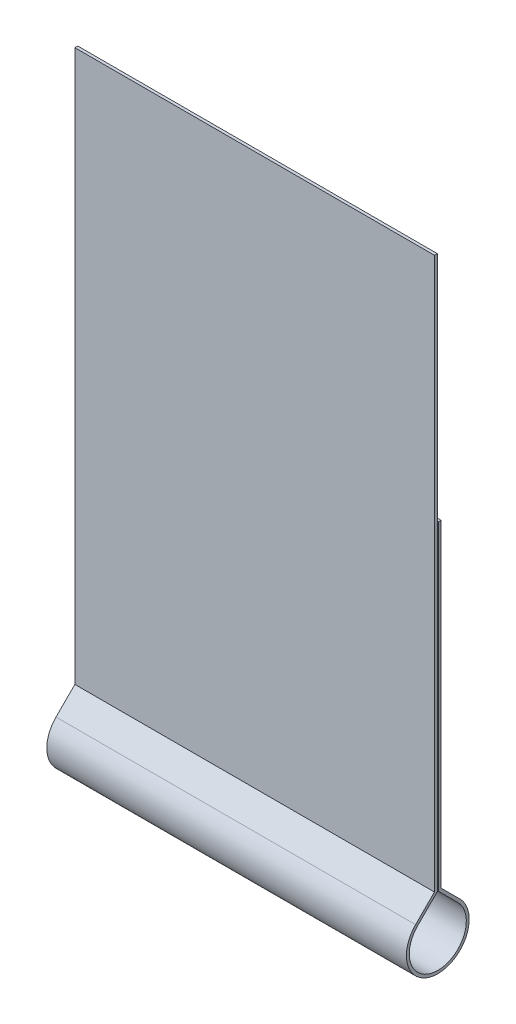
from build123d import *

# Parameters (mm, degrees)
EXTRUDE_THIN1_DEPTH = 9.525


with BuildPart() as part:
    # Sketch1 → Extrude-Thin1 (new, symmetric)
    with BuildSketch(Plane(origin=(0, 0, 0), x_dir=(0, 0, -1), z_dir=(1, 0, 0))):
        with BuildLine():
            Line((-0.1778, 31.39), (-0.1778, 2.175027104))
            Line((-0.1778, 2.175027104), (-1.176413552, 1.176413552))
            ThreePointArc((-1.176413552, 1.176413552), (0, -1.6637), (1.176413552, 1.176413552))
            Line((1.176413552, 1.176413552), (0.1778, 2.175027104))
            Line((0.1778, 2.175027104), (0.1778, 19.05))
            Line((0.1778, 19.05), (0.0254, 19.05))
            Line((0.0254, 19.05), (0.0254, 2.111900957))
            Line((0.0254, 2.111900957), (1.068650478, 1.068650478))
            ThreePointArc((1.068650478, 1.068650478), (0, -1.5113), (-1.068650478, 1.068650478))
            Line((-1.068650478, 1.068650478), (-0.0254, 2.111900957))
            Line((-0.0254, 2.111900957), (-0.0254, 31.39))
            Line((-0.0254, 31.39), (-0.1778, 31.39))
        make_face()
    extrude(amount=EXTRUDE_THIN1_DEPTH, both=True)


solid = part.part
